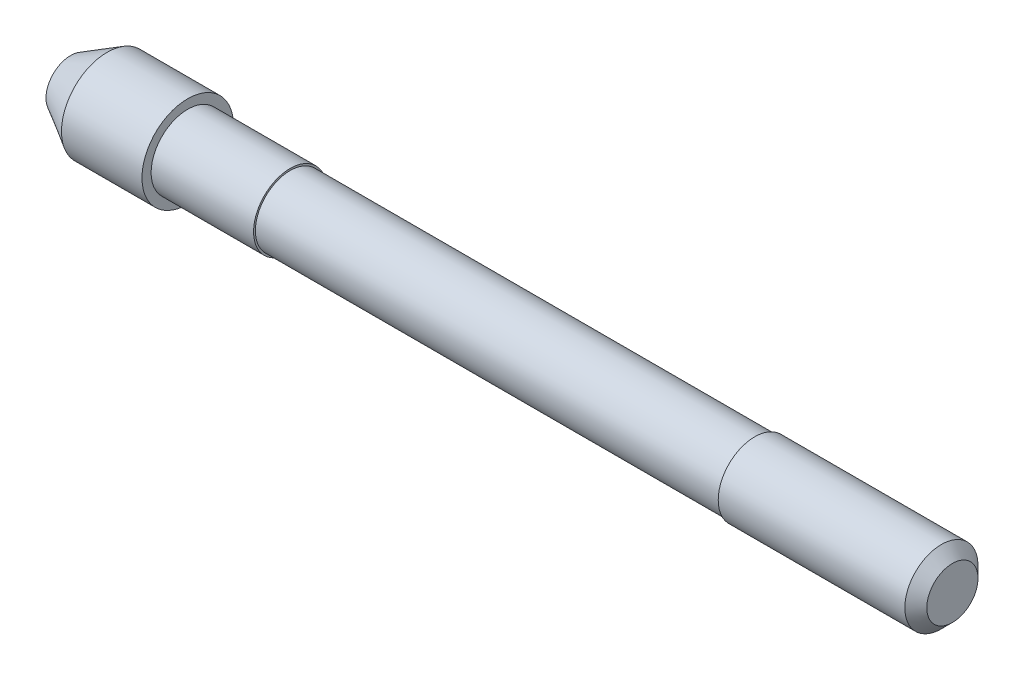
from build123d import *

# Parameters (mm, degrees)
CHANFREIN1_SIZE = 0.3


with BuildPart() as part:
    # Esquisse1 → Révolution1 (revolve)
    with BuildSketch(Plane.XY):
        Polygon((12.05, 0), (12.05, 1), (6.65, 1), (6.65, 0.95), (-6.05, 0.95), (-6.05, 1), (-8.85, 1), (-8.85, 1.25), (-11.05, 1.25), (-12.05, 0.672649731), (-12.05, 0), align=None)
    revolve(axis=Axis((-12.05, 0, 0), (1, 0, 0)))

    # Chanfrein1
    chanfrein1_edges = [part.edges().sort_by_distance(p)[0] for p in [
        (12.05, -1, 0),
    ]]
    chamfer(chanfrein1_edges, length=CHANFREIN1_SIZE)


solid = part.part
